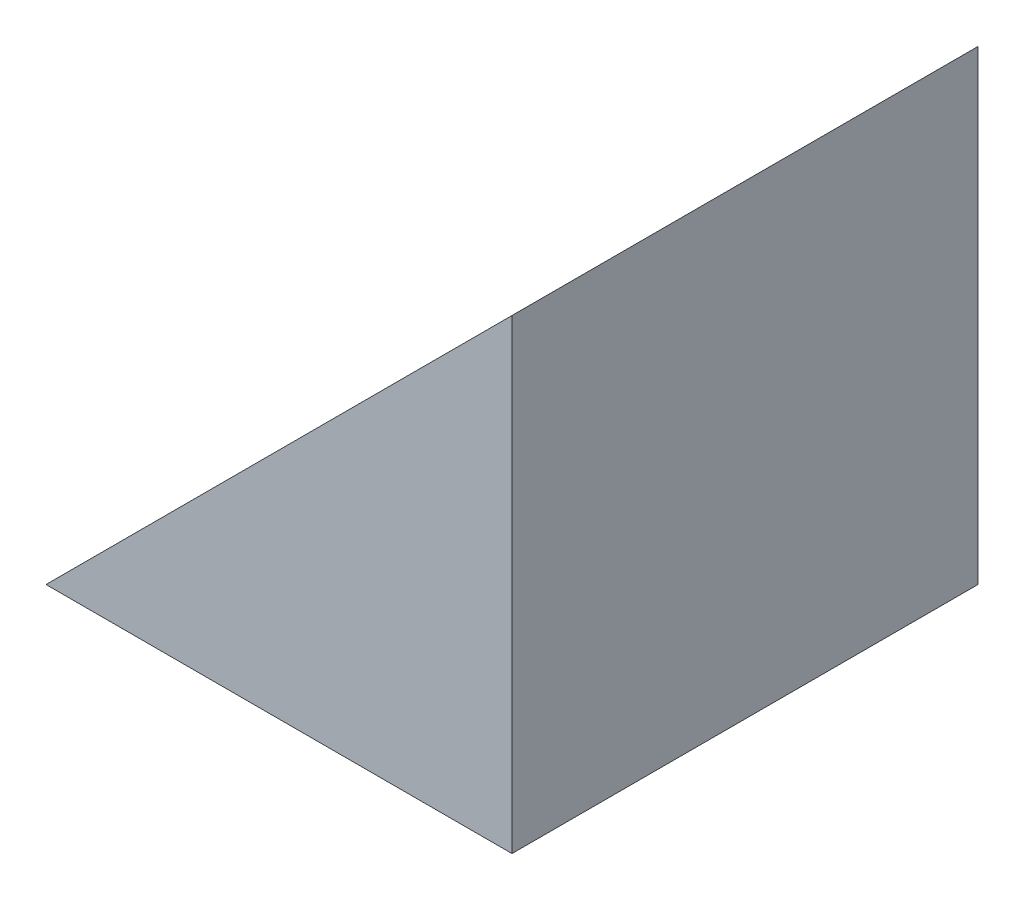
from build123d import *

# Parameters (mm, degrees)
EXTRUDE_1_DEPTH = 6.3


with BuildPart() as part:
    # 草图1 → 凸台-拉伸1 (new body)
    with BuildSketch(Plane.XY):
        Polygon((22.013972028, 16.73016285), (22.013972028, 23.03016285), (15.713972028, 16.73016285), align=None)
    extrude(amount=EXTRUDE_1_DEPTH)


solid = part.part
